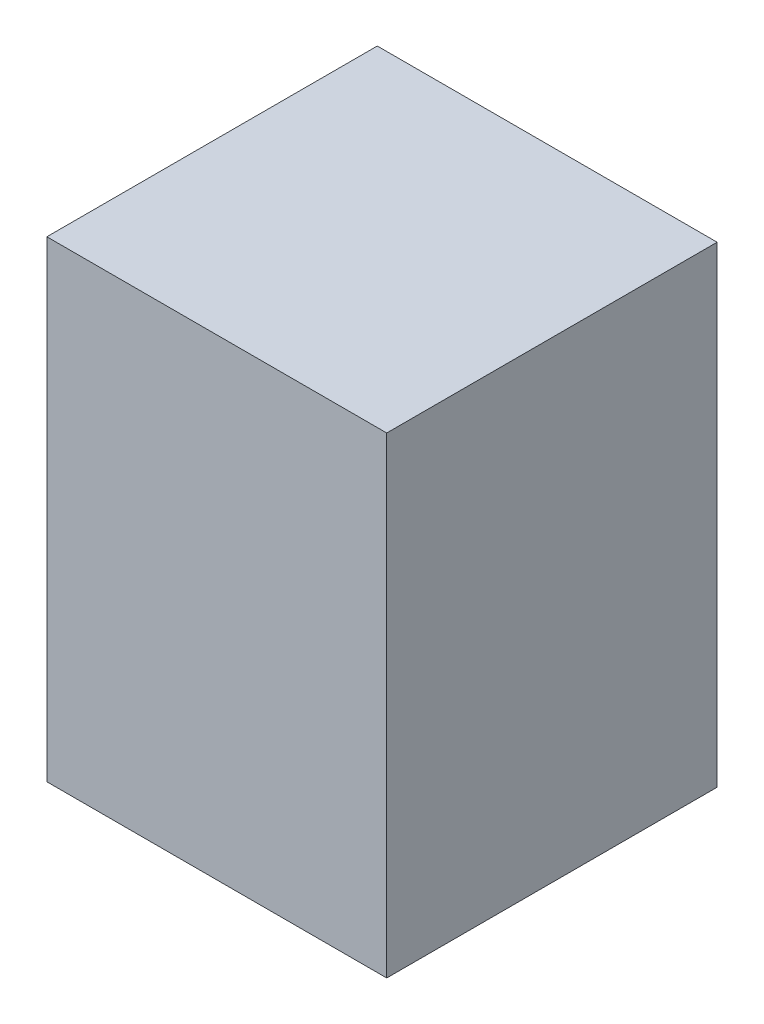
from build123d import *

# Parameters (mm, degrees)
SKETCH_1_W          = 72
SKETCH_1_H          = 100
EXTRUDE_1_DEPTH     = 70
SKETCH_2_R          = 2
CUT_EXTRUDE_1_DEPTH = 10


with BuildPart() as part:
    # Эскиз1 → Бобышка-Вытянуть1 (new body)
    with BuildSketch(Plane.XY):
        with Locations((36, 50)):
            Rectangle(SKETCH_1_W, SKETCH_1_H)
    extrude(amount=EXTRUDE_1_DEPTH)

    # Эскиз2 → Вырез-Вытянуть1 (cut)
    with BuildSketch(Plane.XZ):
        with Locations((40, 50)):
            Circle(SKETCH_2_R)
        with Locations((40, 20)):
            Circle(SKETCH_2_R)
    extrude(amount=-CUT_EXTRUDE_1_DEPTH, mode=Mode.SUBTRACT)


solid = part.part
